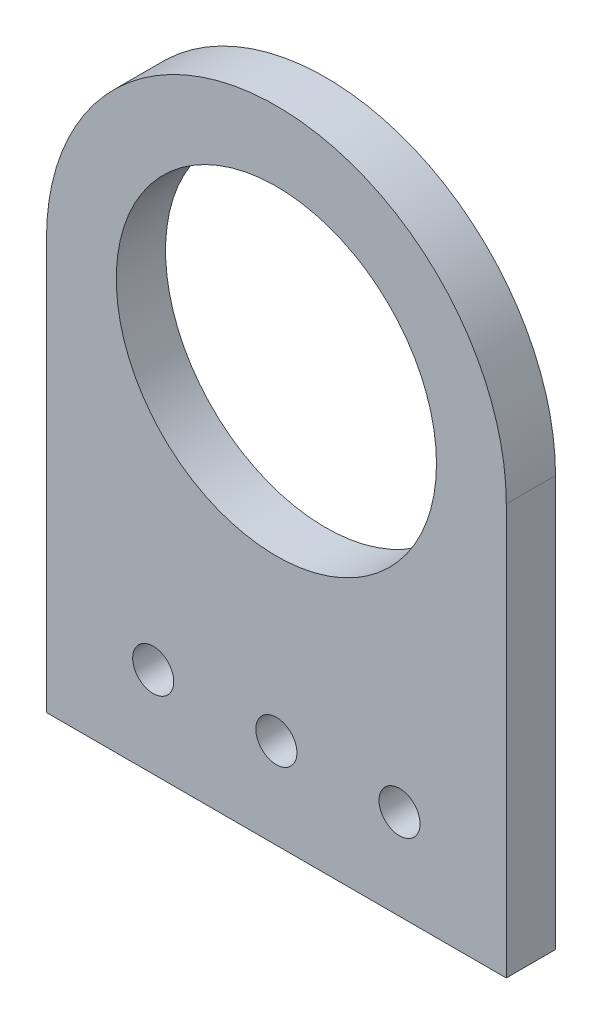
from build123d import *

# Parameters (mm, degrees)
CROQUIS1_R              = 9.75
SALIENTE_EXTRUIR1_DEPTH = 3
CROQUIS2_R              = 1.25
CORTAR_EXTRUIR1_DEPTH   = 3


with BuildPart() as part:
    # Croquis1 → Saliente-Extruir1 (new body)
    with BuildSketch(Plane.XY):
        with BuildLine():
            Line((-14, -25), (14, -25))
            Line((14, -25), (14, 0))
            ThreePointArc((14, 0), (0, 14), (-14, 0))
            Line((-14, 0), (-14, -25))
        make_face()
        Circle(CROQUIS1_R, mode=Mode.SUBTRACT)
    extrude(amount=SALIENTE_EXTRUIR1_DEPTH)

    # Croquis2 → Cortar-Extruir1 (cut)
    with BuildSketch(Plane.XY.offset(3)):
        with Locations((0, -19.5)):
            Circle(CROQUIS2_R)
        with Locations((7.5, -19.5)):
            Circle(CROQUIS2_R)
        with Locations((-7.5, -19.5)):
            Circle(CROQUIS2_R)
    extrude(amount=-CORTAR_EXTRUIR1_DEPTH, mode=Mode.SUBTRACT)


solid = part.part
